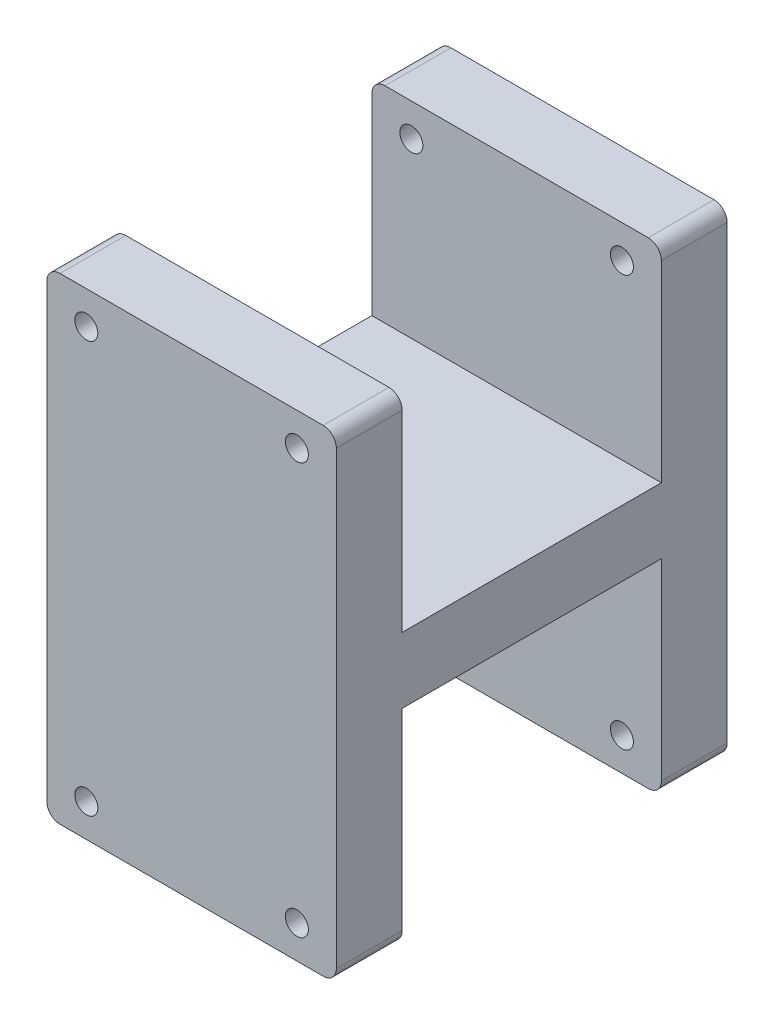
from build123d import *

# Parameters (mm, degrees)
SKETCH_2_W          = 44
SKETCH_2_H          = 72.5
EXTRUDE_1_DEPTH     = 59.4
SKETCH_3_R          = 1.75
CUT_EXTRUDE_1_DEPTH = 60.4
SKETCH_4_W          = 39.4
SKETCH_4_H          = 31.25
CUT_EXTRUDE_2_DEPTH = 45
FILLET_1_R          = 2


with BuildPart() as part:
    # ｽｹｯﾁ2 → ﾎﾞｽ - 押し出し1 (new body)
    with BuildSketch(Plane.XY):
        Rectangle(SKETCH_2_W, SKETCH_2_H)
    extrude(amount=EXTRUDE_1_DEPTH)

    # ｽｹｯﾁ3 → ｶｯﾄ - 押し出し1 (cut, through all)
    with BuildSketch(Plane.XY.offset(59.4)):
        with Locations((-16, 31.25)):
            Circle(SKETCH_3_R)
        with Locations((16, 31.25)):
            Circle(SKETCH_3_R)
        with Locations((16, -31.25)):
            Circle(SKETCH_3_R)
        with Locations((-16, -31.25)):
            Circle(SKETCH_3_R)
    extrude(amount=-CUT_EXTRUDE_1_DEPTH, mode=Mode.SUBTRACT)

    # ｽｹｯﾁ4 → ｶｯﾄ - 押し出し2 (cut, through all)
    with BuildSketch(Plane(origin=(22, 0, 0), x_dir=(0, 0, -1), z_dir=(1, 0, 0))):
        with Locations((-29.7, -20.625)):
            Rectangle(SKETCH_4_W, SKETCH_4_H)
        with Locations((-29.7, 20.625)):
            Rectangle(SKETCH_4_W, SKETCH_4_H)
    extrude(amount=-CUT_EXTRUDE_2_DEPTH, mode=Mode.SUBTRACT)

    # ﾌｨﾚｯﾄ1
    fillet_1_edges = [part.edges().sort_by_distance(p)[0] for p in [
        (22, -36.25, 5),
        (-22, -36.25, 5),
        (-22, 36.25, 5),
        (22, 36.25, 5),
        (-22, 36.25, 54.4),
        (22, 36.25, 54.4),
        (22, -36.25, 54.4),
        (-22, -36.25, 54.4),
    ]]
    fillet(fillet_1_edges, radius=FILLET_1_R)


solid = part.part
